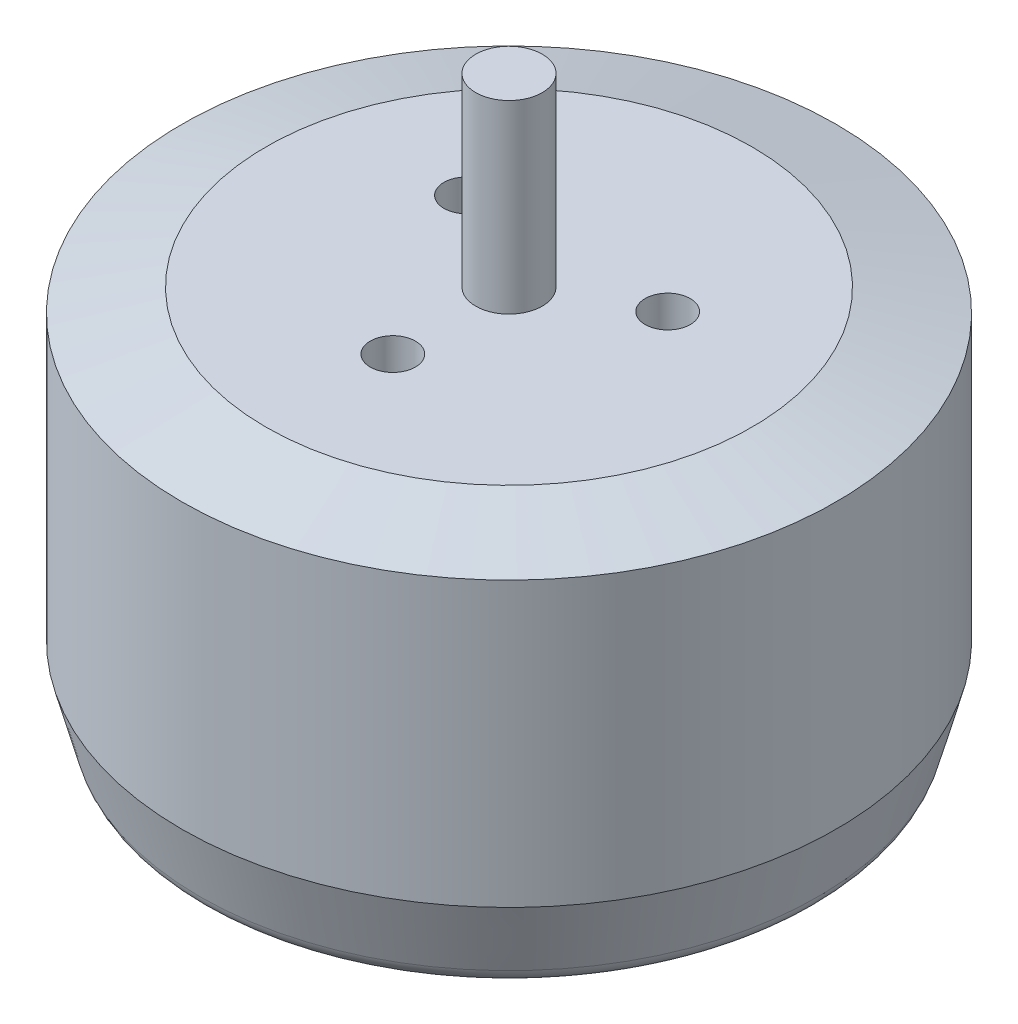
from build123d import *

# Parameters (mm, degrees)
SKETCH_1_R           = 14.5
EXTRUDE_1_DEPTH      = 17.3
SKETCH_2_R           = 1.475
EXTRUDE_2_DEPTH      = 8.2
MM_CLEARANCE_1_D     = 3
MM_CLEARANCE_1_DEPTH = 3
MM_CLEARANCE_1_TIP   = 0.901290929
CHAMFER_1_SIZE       = 1
CHAMFER_1_SIZE2      = 3.732050808
FILLET_1_R           = 1
CHAMFER_2_SIZE       = 1
CHAMFER_2_SIZE2      = 3.732050808
MM_CLEARANCE_2_D     = 2
MM_CLEARANCE_2_DEPTH = 3
MM_CLEARANCE_2_TIP   = 0.600860619


with BuildPart() as part:
    # 草图1 → 凸台-拉伸1 (new body)
    with BuildSketch(Plane(origin=(0, 0, 0), x_dir=(1, 0, 0), z_dir=(0, 1, 0))):
        Circle(SKETCH_1_R)
    extrude(amount=EXTRUDE_1_DEPTH)

    # 草图2 → 凸台-拉伸2 (add)
    with BuildSketch(Plane(origin=(0, 17.3, 0), x_dir=(1, 0, 0), z_dir=(0, 1, 0))):
        Circle(SKETCH_2_R)
    extrude(amount=EXTRUDE_2_DEPTH)

    # 大小mm Clearance 暗销槽口1
    with Locations(Plane(origin=(0, 0, 0), x_dir=(-1, 0, 0), z_dir=(0, -1, 0))):
        with Locations((0, -8), (9.5, 0), (0, 8.000635696), (-9.5, 0)):
            Hole(MM_CLEARANCE_1_D / 2, depth=MM_CLEARANCE_1_DEPTH)
            with Locations((0, 0, -(MM_CLEARANCE_1_DEPTH + MM_CLEARANCE_1_TIP / 2))):  # 118° drill point
                Cone(0, MM_CLEARANCE_1_D / 2, MM_CLEARANCE_1_TIP, mode=Mode.SUBTRACT)

    # 倒角1
    chamfer_1_edges = [part.edges().sort_by_distance(p)[0] for p in [
        (-14.5, 0, 0),
    ]]
    chamfer_1_side = [part.faces().sort_by_distance(p)[0] for p in [
        (0, 0, 7.107e-06),
    ]]
    chamfer(chamfer_1_edges, length=CHAMFER_1_SIZE, length2=CHAMFER_1_SIZE2, reference=chamfer_1_side[0])

    # 圆角1
    fillet_1_edges = [part.edges().sort_by_distance(p)[0] for p in [
        (-13.5, 0, 0),
    ]]
    fillet(fillet_1_edges, radius=FILLET_1_R)

    # 倒角2
    chamfer_2_edges = [part.edges().sort_by_distance(p)[0] for p in [
        (-14.5, 17.3, 0),
    ]]
    chamfer_2_side = [part.faces().sort_by_distance(p)[0] for p in [
        (-14.5, 10.516025404, 0),
    ]]
    chamfer(chamfer_2_edges, length=CHAMFER_2_SIZE, length2=CHAMFER_2_SIZE2, reference=chamfer_2_side[0])

    # 大小mm Clearance 暗销槽口2
    with Locations(Plane(origin=(0, 17.3, 0), x_dir=(1, 0, 0), z_dir=(0, 1, 0))):
        with Locations((-4.460030829, 2.575), (4.460030829, 2.575), (0, -5.15)):
            Hole(MM_CLEARANCE_2_D / 2, depth=MM_CLEARANCE_2_DEPTH)
            with Locations((0, 0, -(MM_CLEARANCE_2_DEPTH + MM_CLEARANCE_2_TIP / 2))):  # 118° drill point
                Cone(0, MM_CLEARANCE_2_D / 2, MM_CLEARANCE_2_TIP, mode=Mode.SUBTRACT)


solid = part.part
